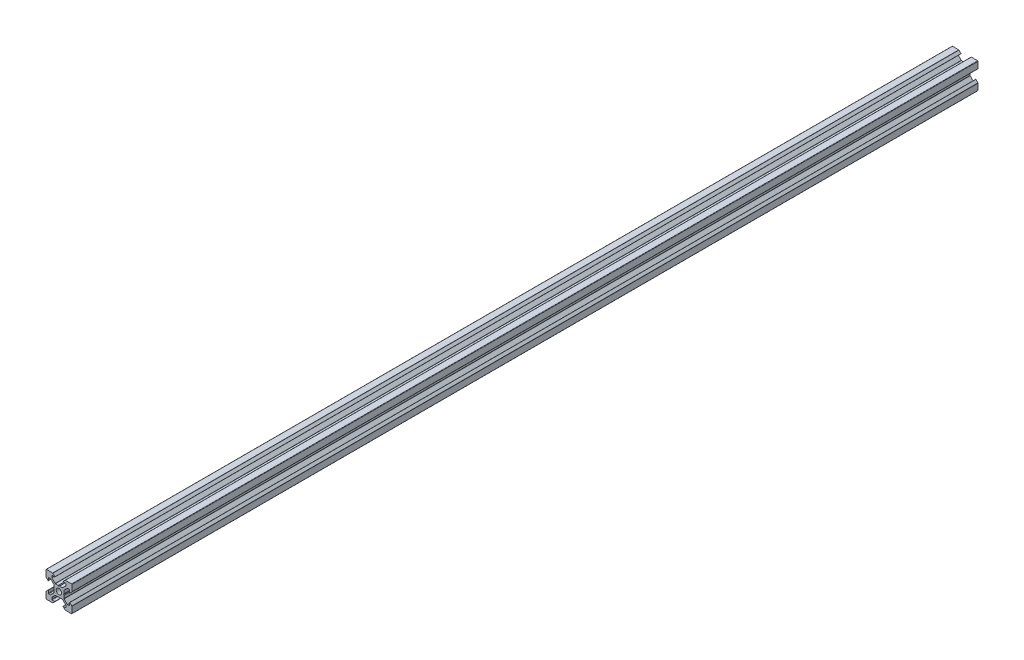
from build123d import *

# Parameters (mm, degrees)
BOSS_EXTRU_1_DEPTH = 700


with BuildPart() as part:
    # Esquisse1 → Boss.-Extru.1 (new body)
    with BuildSketch(Plane.XY):
        with BuildLine():
            Line((18.774857412, -2.895228684), (18.774857412, -4.894568513))
            ThreePointArc((18.774857412, -4.894568513), (18.686989447, -5.106700547), (18.474857412, -5.194568513))
            Line((18.474857412, -5.194568513), (17.259121481, -5.194568513))
            ThreePointArc((17.259121481, -5.194568513), (17.144316451, -5.171732372), (17.046989447, -5.106700547))
            Line((17.046989447, -5.106700547), (14.56338555, -2.62309665))
            ThreePointArc((14.56338555, -2.62309665), (14.498353724, -2.525769645), (14.475517584, -2.410964616))
            Line((14.475517584, -2.410964616), (14.475517584, -0.214843927))
            Line((14.475517584, -0.214843927), (14.175517584, 0.304771316))
            Line((14.175517584, 0.304771316), (14.475517584, 0.824386558))
            Line((14.475517584, 0.824386558), (14.475517584, 3.020507247))
            ThreePointArc((14.475517584, 3.020507247), (14.498353724, 3.135312277), (14.56338555, 3.232639281))
            Line((14.56338555, 3.232639281), (17.046989447, 5.716243178))
            ThreePointArc((17.046989447, 5.716243178), (17.144316451, 5.781275004), (17.259121481, 5.804111144))
            Line((17.259121481, 5.804111144), (18.474857412, 5.804111144))
            ThreePointArc((18.474857412, 5.804111144), (18.686989447, 5.716243178), (18.774857412, 5.504111144))
            Line((18.774857412, 5.504111144), (18.774857412, 3.504771316))
            ThreePointArc((18.774857412, 3.504771316), (18.836589069, 3.412383362), (18.94556809, 3.434060638))
            Line((18.94556809, 3.434060638), (20.486989447, 4.975481994))
            ThreePointArc((20.486989447, 4.975481994), (20.552021272, 5.072808998), (20.574857412, 5.187614028))
            Line((20.574857412, 5.187614028), (20.574857412, 10.004771316))
            ThreePointArc((20.574857412, 10.004771316), (20.486989447, 10.21690335), (20.274857412, 10.304771316))
            Line((20.274857412, 10.304771316), (15.457700125, 10.304771316))
            ThreePointArc((15.457700125, 10.304771316), (15.342895095, 10.281935175), (15.24556809, 10.21690335))
            Line((15.24556809, 10.21690335), (13.704146734, 8.675481994))
            ThreePointArc((13.704146734, 8.675481994), (13.682469459, 8.566502972), (13.774857412, 8.504771316))
            Line((13.774857412, 8.504771316), (15.77419724, 8.504771316))
            ThreePointArc((15.77419724, 8.504771316), (15.986329275, 8.41690335), (16.07419724, 8.204771316))
            Line((16.07419724, 8.204771316), (16.07419724, 6.989035384))
            ThreePointArc((16.07419724, 6.989035384), (16.0513611, 6.874230355), (15.986329275, 6.77690335))
            Line((15.986329275, 6.77690335), (13.502725378, 4.293299453))
            ThreePointArc((13.502725378, 4.293299453), (13.405398373, 4.228267628), (13.290593344, 4.205431487))
            Line((13.290593344, 4.205431487), (11.094472654, 4.205431487))
            Line((11.094472654, 4.205431487), (10.574857412, 3.905431487))
            Line((10.574857412, 3.905431487), (10.05524217, 4.205431487))
            Line((10.05524217, 4.205431487), (7.859121481, 4.205431487))
            ThreePointArc((7.859121481, 4.205431487), (7.744316451, 4.228267628), (7.646989447, 4.293299453))
            Line((7.646989447, 4.293299453), (5.16338555, 6.77690335))
            ThreePointArc((5.16338555, 6.77690335), (5.098353724, 6.874230355), (5.075517584, 6.989035384))
            Line((5.075517584, 6.989035384), (5.075517584, 8.204771316))
            ThreePointArc((5.075517584, 8.204771316), (5.16338555, 8.41690335), (5.375517584, 8.504771316))
            Line((5.375517584, 8.504771316), (7.374857412, 8.504771316))
            ThreePointArc((7.374857412, 8.504771316), (7.467245365, 8.566502972), (7.44556809, 8.675481994))
            Line((7.44556809, 8.675481994), (5.904146734, 10.21690335))
            ThreePointArc((5.904146734, 10.21690335), (5.806819729, 10.281935175), (5.6920147, 10.304771316))
            Line((5.6920147, 10.304771316), (0.874857412, 10.304771316))
            ThreePointArc((0.874857412, 10.304771316), (0.662725378, 10.21690335), (0.574857412, 10.004771316))
            Line((0.574857412, 10.004771316), (0.574857412, 5.187614028))
            ThreePointArc((0.574857412, 5.187614028), (0.597693552, 5.072808998), (0.662725378, 4.975481994))
            Line((0.662725378, 4.975481994), (2.204146734, 3.434060638))
            ThreePointArc((2.204146734, 3.434060638), (2.313125755, 3.412383362), (2.374857412, 3.504771316))
            Line((2.374857412, 3.504771316), (2.374857412, 5.504111144))
            ThreePointArc((2.374857412, 5.504111144), (2.462725378, 5.716243178), (2.674857412, 5.804111144))
            Line((2.674857412, 5.804111144), (3.890593344, 5.804111144))
            ThreePointArc((3.890593344, 5.804111144), (4.005398373, 5.781275004), (4.102725378, 5.716243178))
            Line((4.102725378, 5.716243178), (6.586329275, 3.232639281))
            ThreePointArc((6.586329275, 3.232639281), (6.6513611, 3.135312277), (6.67419724, 3.020507247))
            Line((6.67419724, 3.020507247), (6.67419724, 0.824386558))
            Line((6.67419724, 0.824386558), (6.97419724, 0.304771316))
            Line((6.97419724, 0.304771316), (6.67419724, -0.214843927))
            Line((6.67419724, -0.214843927), (6.67419724, -2.410964616))
            ThreePointArc((6.67419724, -2.410964616), (6.6513611, -2.525769645), (6.586329275, -2.62309665))
            Line((6.586329275, -2.62309665), (4.102725378, -5.106700547))
            ThreePointArc((4.102725378, -5.106700547), (4.005398373, -5.171732372), (3.890593344, -5.194568513))
            Line((3.890593344, -5.194568513), (2.674857412, -5.194568513))
            ThreePointArc((2.674857412, -5.194568513), (2.462725378, -5.106700547), (2.374857412, -4.894568513))
            Line((2.374857412, -4.894568513), (2.374857412, -2.895228684))
            ThreePointArc((2.374857412, -2.895228684), (2.313125755, -2.802840731), (2.204146734, -2.824518006))
            Line((2.204146734, -2.824518006), (0.662725378, -4.365939362))
            ThreePointArc((0.662725378, -4.365939362), (0.597693552, -4.463266367), (0.574857412, -4.578071397))
            Line((0.574857412, -4.578071397), (0.574857412, -9.395228684))
            ThreePointArc((0.574857412, -9.395228684), (0.662725378, -9.607360719), (0.874857412, -9.695228684))
            Line((0.874857412, -9.695228684), (5.6920147, -9.695228684))
            ThreePointArc((5.6920147, -9.695228684), (5.806819729, -9.672392544), (5.904146734, -9.607360719))
            Line((5.904146734, -9.607360719), (7.44556809, -8.065939362))
            ThreePointArc((7.44556809, -8.065939362), (7.467245365, -7.956960341), (7.374857412, -7.895228684))
            Line((7.374857412, -7.895228684), (5.375517584, -7.895228684))
            ThreePointArc((5.375517584, -7.895228684), (5.16338555, -7.807360719), (5.075517584, -7.595228684))
            Line((5.075517584, -7.595228684), (5.075517584, -6.379492753))
            ThreePointArc((5.075517584, -6.379492753), (5.098353724, -6.264687723), (5.16338555, -6.167360719))
            Line((5.16338555, -6.167360719), (7.646989447, -3.683756822))
            ThreePointArc((7.646989447, -3.683756822), (7.744316451, -3.618724996), (7.859121481, -3.595888856))
            Line((7.859121481, -3.595888856), (10.05524217, -3.595888856))
            Line((10.05524217, -3.595888856), (10.574857412, -3.295888856))
            Line((10.574857412, -3.295888856), (11.094472654, -3.595888856))
            Line((11.094472654, -3.595888856), (13.290593344, -3.595888856))
            ThreePointArc((13.290593344, -3.595888856), (13.405398373, -3.618724996), (13.502725378, -3.683756822))
            Line((13.502725378, -3.683756822), (15.986329275, -6.167360719))
            ThreePointArc((15.986329275, -6.167360719), (16.0513611, -6.264687723), (16.07419724, -6.379492753))
            Line((16.07419724, -6.379492753), (16.07419724, -7.595228684))
            ThreePointArc((16.07419724, -7.595228684), (15.986329275, -7.807360719), (15.77419724, -7.895228684))
            Line((15.77419724, -7.895228684), (13.774857412, -7.895228684))
            ThreePointArc((13.774857412, -7.895228684), (13.682469459, -7.956960341), (13.704146734, -8.065939362))
            Line((13.704146734, -8.065939362), (15.24556809, -9.607360719))
            ThreePointArc((15.24556809, -9.607360719), (15.342895095, -9.672392544), (15.457700125, -9.695228684))
            Line((15.457700125, -9.695228684), (20.274857412, -9.695228684))
            ThreePointArc((20.274857412, -9.695228684), (20.486989447, -9.607360719), (20.574857412, -9.395228684))
            Line((20.574857412, -9.395228684), (20.574857412, -4.578071397))
            ThreePointArc((20.574857412, -4.578071397), (20.552021272, -4.463266367), (20.486989447, -4.365939362))
            Line((20.486989447, -4.365939362), (18.94556809, -2.824518006))
            ThreePointArc((18.94556809, -2.824518006), (18.836589069, -2.802840731), (18.774857412, -2.895228684))
        make_face()
        with BuildLine():
            ThreePointArc((10.574857412, -1.795228684), (12.059781653, -1.180152925), (12.674857412, 0.304771316))
            ThreePointArc((12.674857412, 0.304771316), (12.059781653, 1.789695556), (10.574857412, 2.404771316))
            ThreePointArc((10.574857412, 2.404771316), (9.089933172, 1.789695556), (8.474857412, 0.304771316))
            ThreePointArc((8.474857412, 0.304771316), (9.089933172, -1.180152925), (10.574857412, -1.795228684))
        make_face(mode=Mode.SUBTRACT)
    extrude(amount=BOSS_EXTRU_1_DEPTH)


solid = part.part
